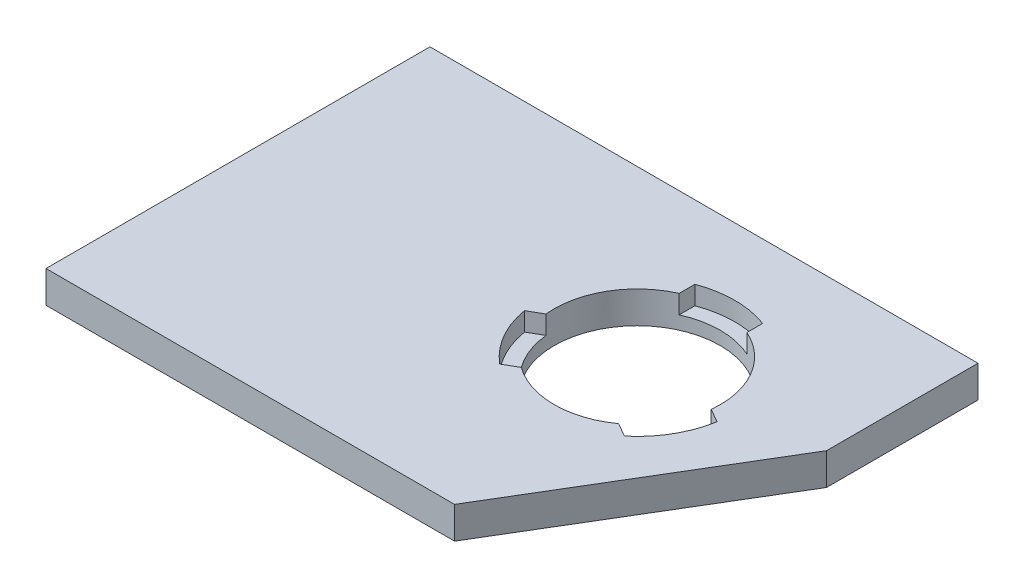
from build123d import *

# Parameters (mm, degrees)
SKETCH1_W           = 82.5
SKETCH1_H           = 57.8
BOSS_EXTRUDE1_DEPTH = 4.8
SKETCH2_R           = 12.5
CUT_EXTRUDE1_DEPTH  = 4.8
CUT_EXTRUDE2_DEPTH  = 2.8


with BuildPart() as part:
    # Sketch1 → Boss-Extrude1 (new body)
    with BuildSketch(Plane(origin=(0, 0, 0), x_dir=(1, 0, 0), z_dir=(0, 1, 0))):
        with Locations((20.883891213, 18.735983264)):
            Rectangle(SKETCH1_W, SKETCH1_H)
    extrude(amount=BOSS_EXTRUDE1_DEPTH)

    # Sketch2 → Cut-Extrude1 (cut)
    with BuildSketch(Plane(origin=(0, 4.8, 0), x_dir=(1, 0, 0), z_dir=(0, 1, 0))):
        with Locations((35.633891213, 22.835983264)):
            Circle(SKETCH2_R)
        Polygon((41.133891213, -10.164016736), (62.133891213, 24.835983264), (62.133891213, -10.164016736), align=None)
    extrude(amount=-CUT_EXTRUDE1_DEPTH, mode=Mode.SUBTRACT)

    # Sketch3 → Cut-Extrude2 (cut)
    with BuildSketch(Plane(origin=(0, 4.8, 0), x_dir=(1, 0, 0), z_dir=(0, 1, 0))):
        with BuildLine():
            ThreePointArc((30.533891213, 34.248257358), (33.026538742, 35.061027766), (35.633891213, 35.335983264))
            Line((35.633891213, 35.335983264), (35.633891213, 37.535983264))
            ThreePointArc((35.633891213, 37.535983264), (33.04334785, 37.30592055), (30.533891213, 36.622933615))
            Line((30.533891213, 36.622933615), (30.533891213, 34.248257358))
        make_face()
        with BuildLine():
            Line((35.633891213, 37.535983264), (35.633891213, 35.335983264))
            ThreePointArc((35.633891213, 35.335983264), (38.241243685, 35.061027766), (40.733891213, 34.248257358))
            Line((40.733891213, 34.248257358), (40.733891213, 36.622933615))
            ThreePointArc((40.733891213, 36.622933615), (38.224434576, 37.30592055), (35.633891213, 37.535983264))
        make_face()
        with BuildLine():
            ThreePointArc((48.067210494, 21.546575776), (47.524766551, 18.981494489), (46.459208761, 16.585983264))
            Line((46.459208761, 16.585983264), (48.364464649, 15.485983264))
            ThreePointArc((48.364464649, 15.485983264), (49.460496176, 17.844490982), (50.123740459, 20.359237647))
            Line((50.123740459, 20.359237647), (48.067210494, 21.546575776))
        make_face()
        with BuildLine():
            Line((48.364464649, 15.485983264), (46.459208761, 16.585983264))
            ThreePointArc((46.459208761, 16.585983264), (44.917414079, 14.465427535), (42.967210494, 12.713116657))
            Line((42.967210494, 12.713116657), (45.023740459, 11.525778528))
            ThreePointArc((45.023740459, 11.525778528), (46.869952814, 13.357538258), (48.364464649, 15.485983264))
        make_face()
        with BuildLine():
            Line((22.903317778, 15.485983264), (24.808573666, 16.585983264))
            ThreePointArc((24.808573666, 16.585983264), (23.743015876, 18.981494489), (23.200571933, 21.546575776))
            Line((23.200571933, 21.546575776), (21.144041968, 20.359237647))
            ThreePointArc((21.144041968, 20.359237647), (21.80728625, 17.844490982), (22.903317778, 15.485983264))
        make_face()
        with BuildLine():
            ThreePointArc((28.300571933, 12.713116657), (26.350368348, 14.465427535), (24.808573666, 16.585983264))
            Line((24.808573666, 16.585983264), (22.903317778, 15.485983264))
            ThreePointArc((22.903317778, 15.485983264), (24.397829613, 13.357538258), (26.244041968, 11.525778528))
            Line((26.244041968, 11.525778528), (28.300571933, 12.713116657))
        make_face()
    extrude(amount=-CUT_EXTRUDE2_DEPTH, mode=Mode.SUBTRACT)


solid = part.part
